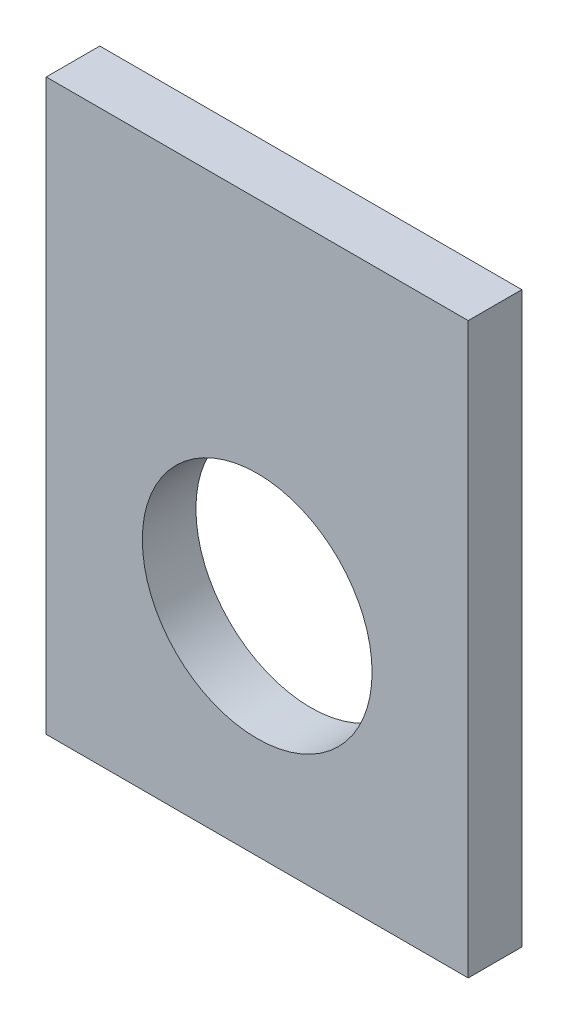
from build123d import *

# Parameters (mm, degrees)
SKETCH1_W           = 25.2
SKETCH1_H           = 34
BOSS_EXTRUDE1_DEPTH = 3.2
CUT_EXTRUDE1_REACH  = 5.2
SKETCH4_R           = 6.86


with BuildPart() as part:
    # Sketch1 → Boss-Extrude1 (new body)
    with BuildSketch(Plane.XY):
        Rectangle(SKETCH1_W, SKETCH1_H)
    extrude(amount=BOSS_EXTRUDE1_DEPTH)

    # Sketch4 → Cut-Extrude1 (cut, up to next)
    with BuildSketch(Plane.XY.offset(3.2), mode=Mode.PRIVATE) as cut_extrude1_sk1:
        with Locations((0, -4.06)):
            Circle(SKETCH4_R)
    cut_extrude1_tool1 = extrude(cut_extrude1_sk1.sketch, amount=-CUT_EXTRUDE1_REACH, mode=Mode.PRIVATE) & part.part
    add(cut_extrude1_tool1.solids().sort_by_distance((0, -4.06, 3.2))[0], mode=Mode.SUBTRACT)


solid = part.part
